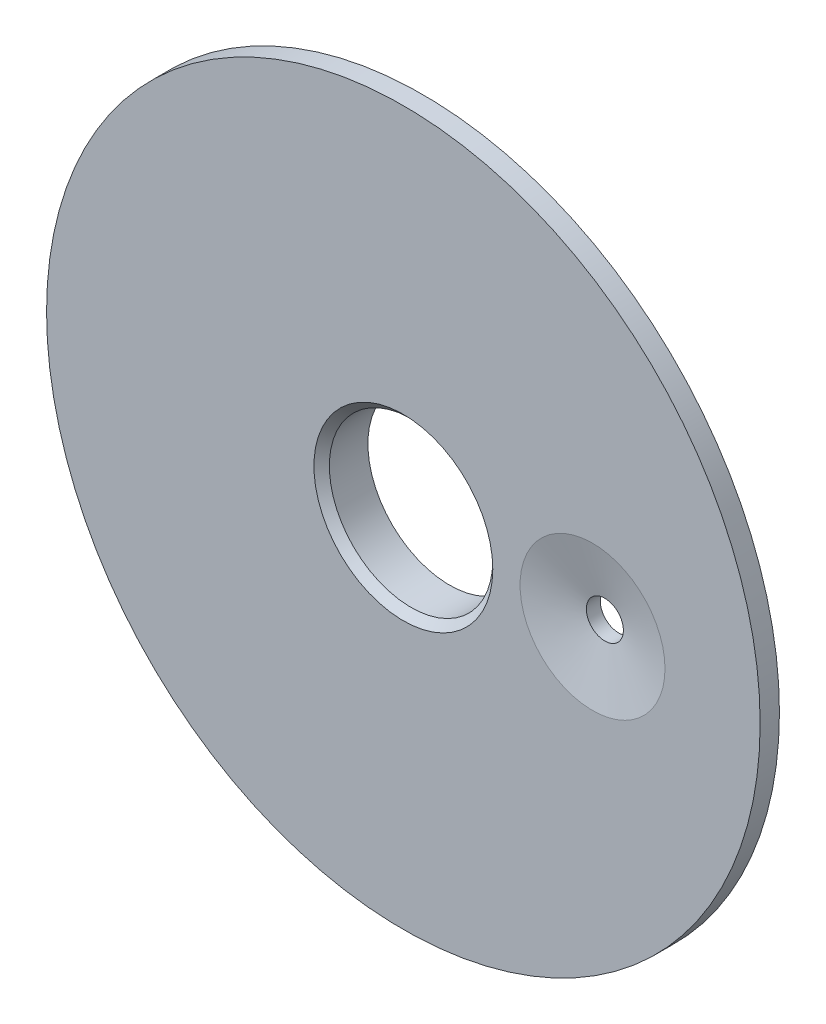
from build123d import *

# Parameters (mm, degrees)
SKETCH_1_R          = 23.14
EXTRUDE_1_DEPTH     = 1.25
SKETCH_2_R          = 20.2
EXTRUDE_2_DEPTH     = 1.75
CUT_EXTRUDE_1_DEPTH = 1.75
CUT_EXTRUDE_START   = 1.25
SKETCH_5_R          = 1.20000014
SKETCH_5_R_2        = 5.3
CUT_EXTRUDE_2_DEPTH = 3
CHAMFER_1_SIZE      = 3.5
CHAMFER_1_SIZE2     = 0.8
CHAMFER_2_SIZE      = 0.5
CUT_EXTRUDE_START_2 = -1.75
CUT_EXTRUDE_3_DEPTH = 1.3


with BuildPart() as part:
    # 草图1 → 凸台-拉伸1 (new body)
    with BuildSketch(Plane.XY):
        with Locations((91.99900066, 78.41000066)):
            Circle(SKETCH_1_R)
    extrude(amount=EXTRUDE_1_DEPTH)

    # 草图2 → 凸台-拉伸2 (add)
    with BuildSketch(Plane.XY):
        with Locations((91.99900066, 78.41000066)):
            Circle(SKETCH_2_R)
    extrude(amount=-EXTRUDE_2_DEPTH)

    # 草图3 → 切除-拉伸1 (cut)
    with BuildSketch(Plane.XY):
        with BuildLine():
            Line((99.695, 96.266), (99.695, 97.658416258))
            ThreePointArc((99.695, 97.658416258), (92.012378583, 99.139588259), (84.327969421, 97.66771932))
            Line((84.327969421, 97.66771932), (84.327969421, 94.233969421))
            Line((84.327969421, 94.233969421), (84.074, 93.98))
            Line((84.074, 93.98), (79.629, 93.98))
            Line((79.629, 93.98), (79.248, 93.599))
            Line((79.248, 93.599), (79.248, 91.059))
            Line((79.248, 91.059), (78.74, 90.551))
            Line((78.74, 90.551), (78.74, 88.138))
            Line((78.74, 88.138), (79.121, 87.757))
            Line((79.121, 87.757), (83.566, 87.757))
            Line((83.566, 87.757), (84.201, 87.122))
            Line((84.201, 87.122), (84.201, 85.471))
            Line((84.201, 85.471), (84.455, 85.217))
            Line((84.455, 85.217), (86.233, 85.217))
            Line((86.233, 85.217), (86.752296117, 84.697830406))
            Line((86.752296117, 84.697830406), (96.762680157, 84.697680157))
            Line((96.762680157, 84.697680157), (97.282, 85.217))
            Line((97.282, 85.217), (99.314, 85.217))
            Line((99.314, 85.217), (99.568, 85.471))
            Line((99.568, 85.471), (99.568, 85.725))
            Line((99.568, 85.725), (99.568, 86.741))
            Line((99.568, 86.741), (99.695, 86.868))
            Line((99.695, 86.868), (104.14, 86.868))
            Line((104.14, 86.868), (104.648, 87.376))
            Line((104.648, 87.376), (104.648, 93.472))
            Line((104.648, 93.472), (104.14, 93.98))
            Line((104.14, 93.98), (101.854, 93.98))
            Line((101.854, 93.98), (101.6, 94.234))
            Line((101.6, 94.234), (101.6, 95.631))
            Line((101.6, 95.631), (101.219, 96.012))
            Line((101.219, 96.012), (99.949, 96.012))
            Line((99.949, 96.012), (99.695, 96.266))
        make_face()
    extrude(amount=-CUT_EXTRUDE_1_DEPTH, mode=Mode.SUBTRACT)

    # 草图5 → 切除-拉伸2 (cut)
    with BuildSketch(Plane.XY.offset(CUT_EXTRUDE_START)):
        with Locations((104.267, 78.41000066)):
            Circle(SKETCH_5_R)
        with Locations((91.99900066, 78.41000066)):
            Circle(SKETCH_5_R_2)
    extrude(amount=-CUT_EXTRUDE_2_DEPTH, mode=Mode.SUBTRACT)

    # 倒角1
    chamfer_1_edges = [part.edges().sort_by_distance(p)[0] for p in [
        (103.06699986, 78.41000066, 1.25),
    ]]
    chamfer_1_side = [part.faces().sort_by_distance(p)[0] for p in [
        (69.513498697, 78.41000066, 1.25),
    ]]
    chamfer(chamfer_1_edges, length=CHAMFER_1_SIZE, length2=CHAMFER_1_SIZE2, reference=chamfer_1_side[0])

    # 倒角2
    chamfer_2_edges = [part.edges().sort_by_distance(p)[0] for p in [
        (86.69900066, 78.41000066, 1.25),
    ]]
    chamfer(chamfer_2_edges, length=CHAMFER_2_SIZE)

    # 草图6 → 切除-拉伸3 (cut)
    with BuildSketch(Plane.XY.offset(CUT_EXTRUDE_START_2)):
        Polygon((101.727, 82.931), (101.346, 82.55), (101.346, 74.422), (101.6, 74.168), (106.68, 74.168), (107.315, 74.803), (107.315, 82.423), (106.807, 82.931), align=None)
    extrude(amount=CUT_EXTRUDE_3_DEPTH, mode=Mode.SUBTRACT)


solid = part.part
